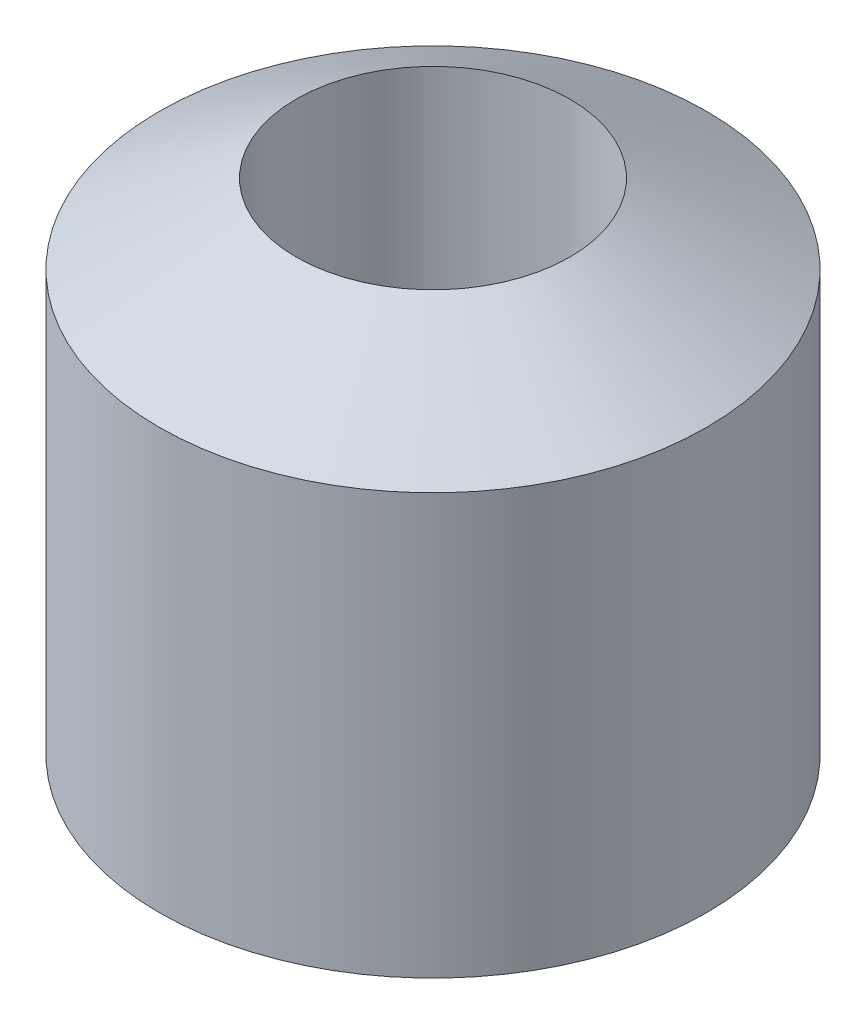
from build123d import *


with BuildPart() as part:
    # Sketch1 → Revolve1 (revolve)
    with BuildSketch(Plane(origin=(0, 0, 0), x_dir=(0, 0, -1), z_dir=(1, 0, 0))):
        Polygon((14, 29.582903769), (14, -29.582903769), (28, -21.5), (28, 21.5), align=None)
    revolve(axis=Axis((0, 32.360655738, 0), (0, -1, 0)))


solid = part.part
